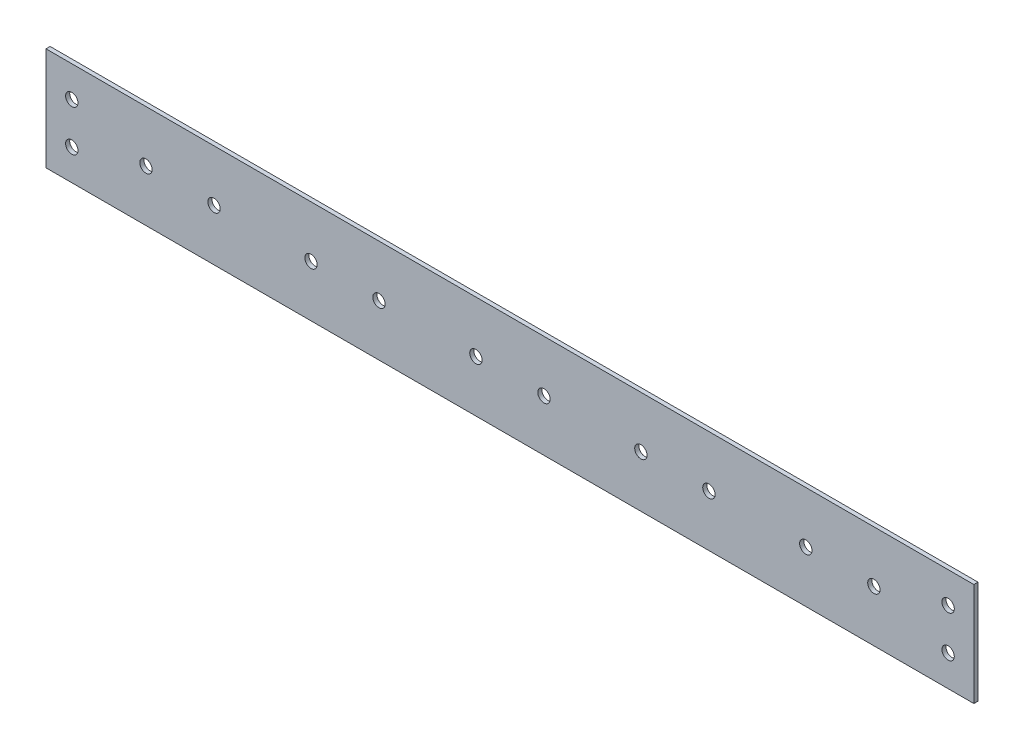
from build123d import *

# Parameters (mm, degrees)
SKETCH_1_W          = 450
SKETCH_1_H          = 50
SKETCH_1_R          = 3
EXTRUDE_1_DEPTH     = 2
SKETCH_2_R          = 3
CUT_EXTRUDE_1_DEPTH = 3


with BuildPart() as part:
    # Эскиз1 → Бобышка-Вытянуть1 (new body)
    with BuildSketch(Plane.XY):
        with Locations((171.141952991, -2.602230483)):
            Rectangle(SKETCH_1_W, SKETCH_1_H)
        with Locations((-5.358047009, -2.602230483)):
            Circle(SKETCH_1_R, mode=Mode.SUBTRACT)
        with Locations((27.641952991, -2.602230483)):
            Circle(SKETCH_1_R, mode=Mode.SUBTRACT)
        with Locations((74.641952991, -2.602230483)):
            Circle(SKETCH_1_R, mode=Mode.SUBTRACT)
        with Locations((107.641952991, -2.602230483)):
            Circle(SKETCH_1_R, mode=Mode.SUBTRACT)
        with Locations((154.641952991, -2.602230483)):
            Circle(SKETCH_1_R, mode=Mode.SUBTRACT)
        with Locations((187.641952991, -2.602230483)):
            Circle(SKETCH_1_R, mode=Mode.SUBTRACT)
        with Locations((234.641952991, -2.602230483)):
            Circle(SKETCH_1_R, mode=Mode.SUBTRACT)
        with Locations((267.641952991, -2.602230483)):
            Circle(SKETCH_1_R, mode=Mode.SUBTRACT)
        with Locations((314.641952991, -2.602230483)):
            Circle(SKETCH_1_R, mode=Mode.SUBTRACT)
        with Locations((347.641952991, -2.602230483)):
            Circle(SKETCH_1_R, mode=Mode.SUBTRACT)
    extrude(amount=EXTRUDE_1_DEPTH)

    # Эскиз2 → Вырез-Вытянуть1 (cut, through all)
    with BuildSketch(Plane.XY.offset(2)):
        with Locations((-41.358047009, 7.397769517)):
            Circle(SKETCH_2_R)
        with Locations(Location((-41.358047009, -12.602230483, 0), (0, 0, 180))):  # turned: the seam where the file's is
            Circle(SKETCH_2_R)
        with Locations((383.641952991, -12.602230483)):
            Circle(SKETCH_2_R)
        with Locations(Location((383.641952991, 7.397769517, 0), (0, 0, 180))):  # turned: the seam where the file's is
            Circle(SKETCH_2_R)
    extrude(amount=-CUT_EXTRUDE_1_DEPTH, mode=Mode.SUBTRACT)


solid = part.part
